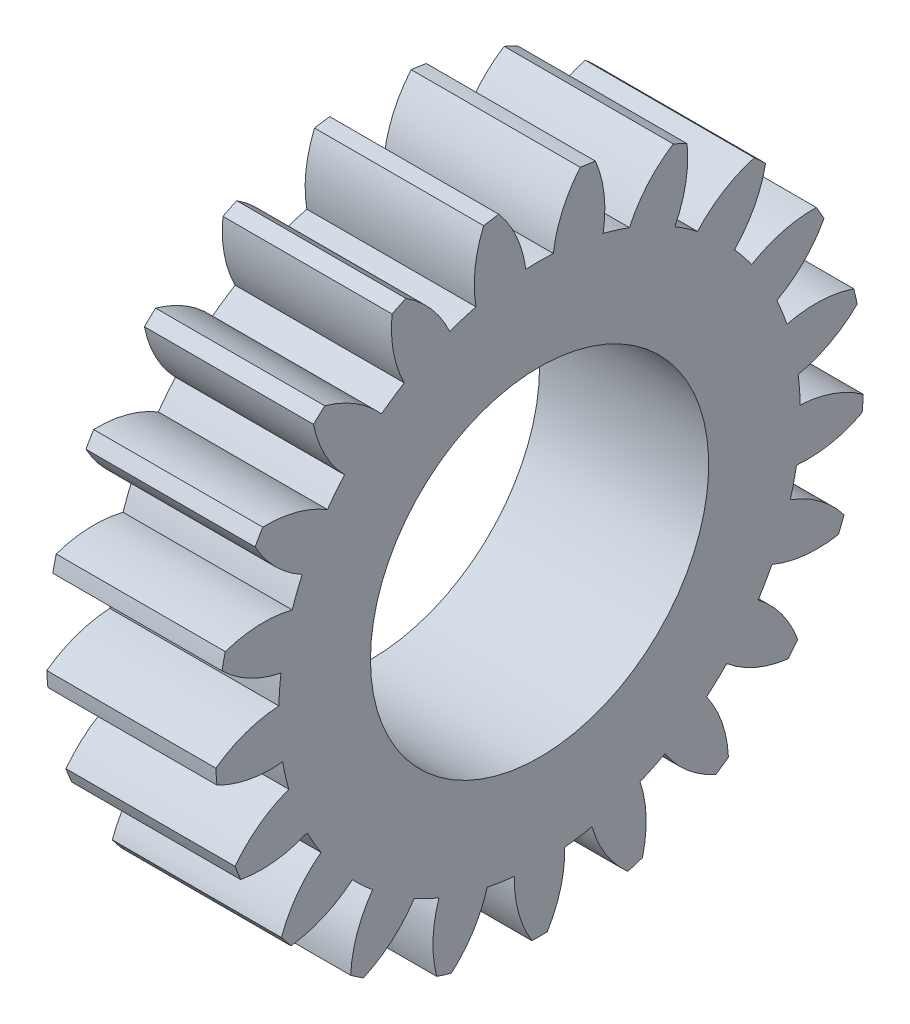
from build123d import *

# Parameters (mm, degrees)
BASPROSKE_W     = 12
BASPROSKE_H     = 23
TOOTHCUT_DEPTH  = 35.669871647
TEETHCUTS_COUNT = 21
TEETHCUTS_ANGLE = 342.857142857
BORSKE_R        = 12
BORE_DEPTH      = 50.0000508


with BuildPart() as part:
    # BasProSke → Base-Revolve (revolve)
    with BuildSketch(Plane(origin=(0, 0, 0), x_dir=(1, 0, 0), z_dir=(0, 1, 0)), mode=Mode.PRIVATE) as base_revolve_sk:
        with Locations((6, 11.5)):
            Rectangle(BASPROSKE_W, BASPROSKE_H)
    revolve(base_revolve_sk.sketch.rotate(Axis((-10, 0, 0), (1, 0, 0)), 180), axis=Axis((-10, 0, 0), (1, 0, 0)))

    # TooCutSke → ToothCut (cut, through all)
    with BuildSketch(Plane(origin=(0, 0, 0), x_dir=(0, 0, -1), z_dir=(1, 0, 0))):
        with BuildLine():
            ThreePointArc((0.976779145, 18.473194188), (0, 18.499), (-0.976779145, 18.473194188))
            ThreePointArc((-0.976779145, 18.473194188), (-1.625451341, 20.797249275), (-2.90802115, 22.841025768))
            ThreePointArc((-2.90802115, 22.841025768), (0, 23.0254), (2.90802115, 22.841025768))
            ThreePointArc((2.90802115, 22.841025768), (1.625451341, 20.797249275), (0.976779145, 18.473194188))
        make_face()
    toothcut = extrude(amount=TOOTHCUT_DEPTH, mode=Mode.SUBTRACT)

    # TeethCuts: ToothCut ×21 about axis
    teethcuts_axis = Axis((-10, 0, 0), (1, 0, 0))
    for i in range(1, TEETHCUTS_COUNT):
        add(toothcut.rotate(teethcuts_axis, i * TEETHCUTS_ANGLE / (TEETHCUTS_COUNT - 1)), mode=Mode.SUBTRACT)

    # BorSke → Bore (cut, symmetric)
    with BuildSketch(Plane(origin=(0, 0, 0), x_dir=(0, 0, -1), z_dir=(1, 0, 0))):
        with Locations(Location((0, 0, 0), (0, 0, 180))):
            Circle(BORSKE_R)
    extrude(amount=BORE_DEPTH, both=True, mode=Mode.SUBTRACT)


solid = part.part
